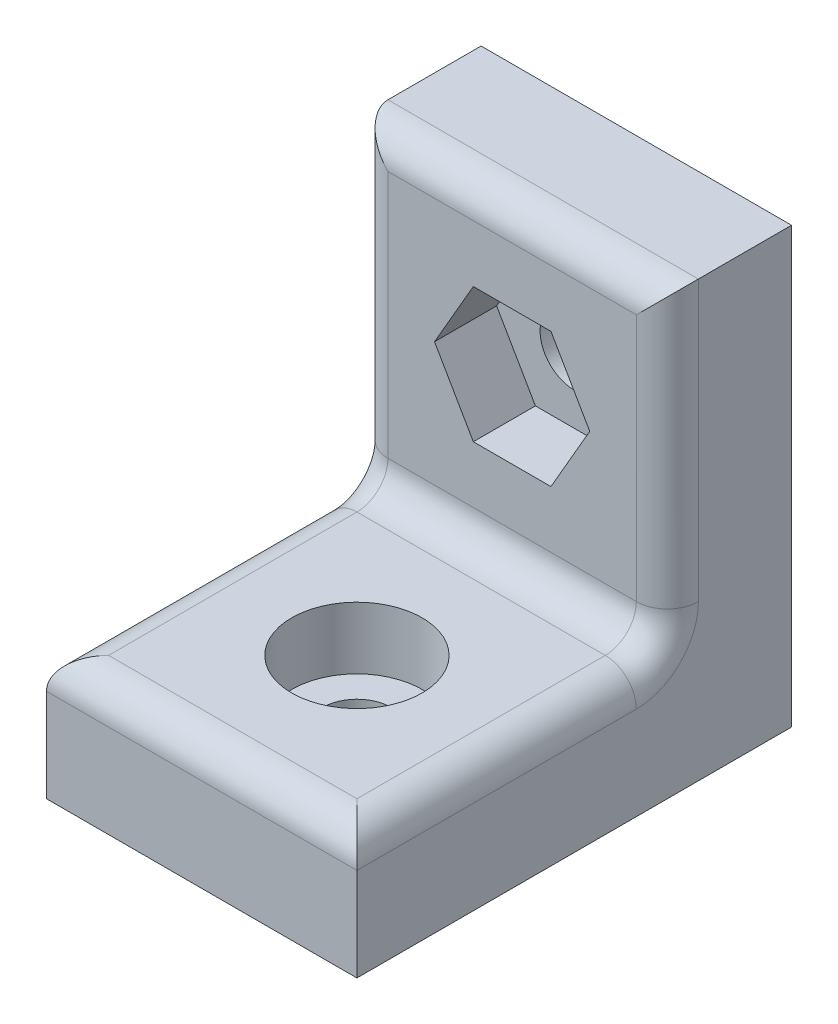
from build123d import *

# Parameters (mm, degrees)
ESQUISSE1_W             = 10
ESQUISSE1_H             = 14
BOSS_EXTRU_1_DEPTH      = 4
ESQUISSE2_W             = 10
ESQUISSE2_H             = 4
BOSS_EXTRU_2_DEPTH      = 10
ESQUISSE3_R             = 1.1
ENL_V_MAT_EXTRU_1_DEPTH = 5
CONG_1_R                = 1
ESQUISSE4_R             = 1.1
ENL_V_MAT_EXTRU_2_DEPTH = 5
ENL_V_MAT_EXTRU_3_DEPTH = 2
ESQUISSE6_R             = 2.1
ENL_V_MAT_EXTRU_4_DEPTH = 2


with BuildPart() as part:
    # Esquisse1 → Boss.-Extru.1 (new body)
    with BuildSketch(Plane.XY):
        with Locations((0, 7)):
            Rectangle(ESQUISSE1_W, ESQUISSE1_H)
    extrude(amount=BOSS_EXTRU_1_DEPTH)

    # Esquisse2 → Boss.-Extru.2 (add)
    with BuildSketch(Plane.XY.offset(4)):
        with Locations((0, 2)):
            Rectangle(ESQUISSE2_W, ESQUISSE2_H)
    extrude(amount=BOSS_EXTRU_2_DEPTH)

    # Esquisse3 → Enlèv. mat.-Extru.1 (cut, through all)
    with BuildSketch(Plane.XY.offset(4)):
        with Locations((0, 9)):
            Circle(ESQUISSE3_R)
    extrude(amount=-ENL_V_MAT_EXTRU_1_DEPTH, mode=Mode.SUBTRACT)

    # Congé1
    cong_1_edges = [part.edges().sort_by_distance(p)[0] for p in [
        (5, 9, 4),
        (-5, 4, 9),
        (0, 4, 4),
        (5, 4, 9),
        (0, 14, 4),
        (0, 4, 14),
        (-5, 9, 4),
    ]]
    fillet(cong_1_edges, radius=CONG_1_R)

    # Esquisse4 → Enlèv. mat.-Extru.2 (cut, through all)
    with BuildSketch(Plane(origin=(0, 4, 0), x_dir=(1, 0, 0), z_dir=(0, 1, 0))):
        with Locations(Location((0, -9, 0), (0, 0, 270))):  # turned: the seam where the file's is
            Circle(ESQUISSE4_R)
    extrude(amount=-ENL_V_MAT_EXTRU_2_DEPTH, mode=Mode.SUBTRACT)

    # Esquisse5 → Enlèv. mat.-Extru.3 (cut)
    with BuildSketch(Plane.XY.offset(4)):
        Polygon((1.25, 6.834936491), (2.5, 9), (1.25, 11.165063509), (-1.25, 11.165063509), (-2.5, 9), (-1.25, 6.834936491), align=None)
    extrude(amount=-ENL_V_MAT_EXTRU_3_DEPTH, mode=Mode.SUBTRACT)

    # Esquisse6 → Enlèv. mat.-Extru.4 (cut)
    with BuildSketch(Plane(origin=(0, 4, 0), x_dir=(1, 0, 0), z_dir=(0, 1, 0))):
        with Locations(Location((0, -9, 0), (0, 0, 270))):  # turned: the seam where the file's is
            Circle(ESQUISSE6_R)
    extrude(amount=-ENL_V_MAT_EXTRU_4_DEPTH, mode=Mode.SUBTRACT)


solid = part.part
